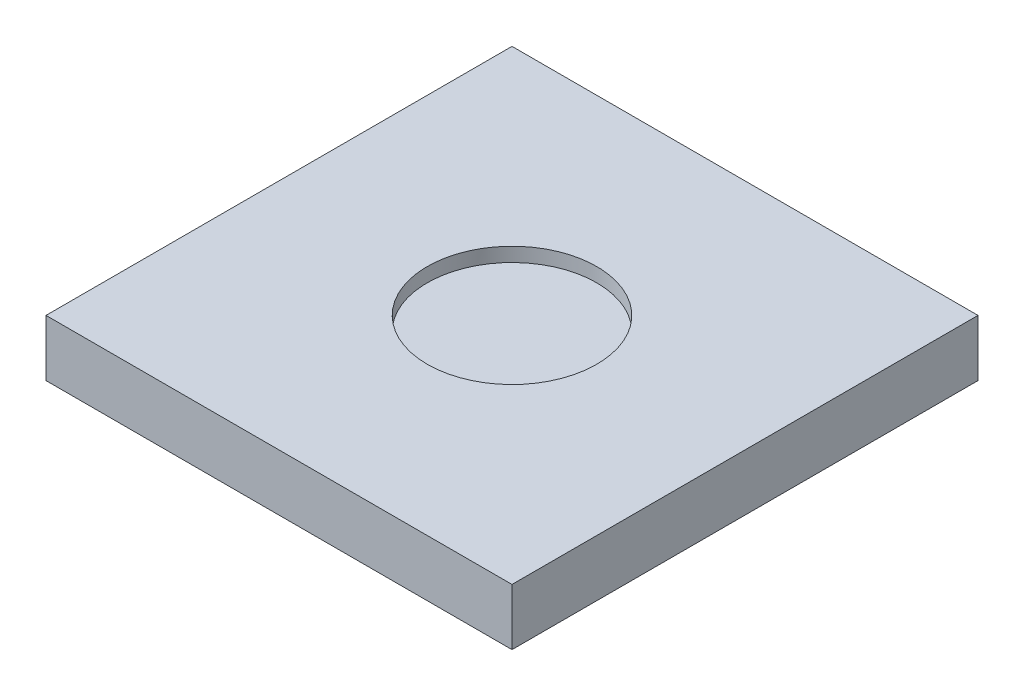
from build123d import *

# Parameters (mm, degrees)
SKETCH1_W           = 33
SKETCH1_H           = 33
SKETCH1_W_2         = 31
SKETCH1_H_2         = 31
BOSS_EXTRUDE1_DEPTH = 3
SKETCH2_W           = 33
SKETCH2_H           = 33
BOSS_EXTRUDE2_DEPTH = 1
SKETCH3_R           = 6
CUT_EXTRUDE1_DEPTH  = 5
SKETCH4_R           = 8
BOSS_EXTRUDE3_DEPTH = 1


with BuildPart() as part:
    # Sketch1 → Boss-Extrude1 (new body)
    with BuildSketch(Plane(origin=(0, 0, 0), x_dir=(1, 0, 0), z_dir=(0, 1, 0))):
        Rectangle(SKETCH1_W, SKETCH1_H)
        Rectangle(SKETCH1_W_2, SKETCH1_H_2, mode=Mode.SUBTRACT)
    extrude(amount=BOSS_EXTRUDE1_DEPTH)

    # Sketch2 → Boss-Extrude2 (add)
    with BuildSketch(Plane(origin=(0, 3, 0), x_dir=(1, 0, 0), z_dir=(0, 1, 0))):
        Rectangle(SKETCH2_W, SKETCH2_H)
    extrude(amount=BOSS_EXTRUDE2_DEPTH)

    # Sketch3 → Cut-Extrude1 (cut, through all)
    with BuildSketch(Plane(origin=(0, 4, 0), x_dir=(1, 0, 0), z_dir=(0, 1, 0))):
        Circle(SKETCH3_R)
    extrude(amount=-CUT_EXTRUDE1_DEPTH, mode=Mode.SUBTRACT)

    # Sketch4 → Boss-Extrude3 (add)
    with BuildSketch(Plane.XZ.offset(-3)):
        Circle(SKETCH4_R)
    extrude(amount=BOSS_EXTRUDE3_DEPTH)


solid = part.part
